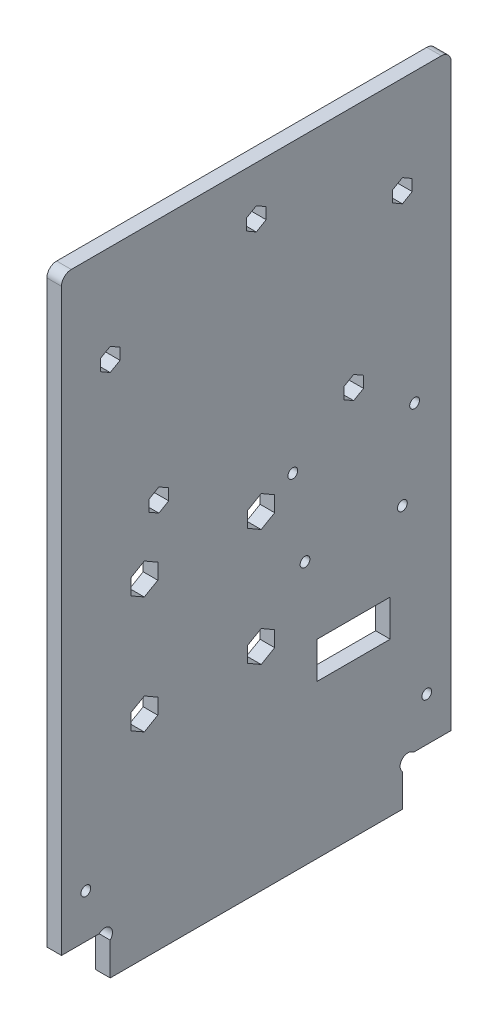
from build123d import *

# Parameters (mm, degrees)
EXTRUSION1_DEPTH        = 3
ESQUISSE2_R             = 1
ESQUISSE2_R_2           = 1.5
ENL_V_MAT_EXTRU_1_DEPTH = 4
ESQUISSE3_W             = 15
ESQUISSE3_H             = 7.5
ENL_V_MAT_EXTRU_2_DEPTH = 4
ESQUISSE4_R             = 1
ENL_V_MAT_EXTRU_3_DEPTH = 4
ENL_V_MAT_EXTRU_4_DEPTH = 4
CONG_1_R                = 2
ESQUISSE6_R             = 1
ENL_V_MAT_EXTRU_5_DEPTH = 4


with BuildPart() as part:
    # Esquisse1 → Extrusion1 (new body)
    with BuildSketch(Plane(origin=(0, 0, 0), x_dir=(0, 0, -1), z_dir=(1, 0, 0))):
        with BuildLine():
            Line((10, 6.7372583), (10, 0))
            Line((10, 0), (70, 0))
            Line((70, 0), (70, 6.7372583))
            ThreePointArc((70, 6.7372583), (70, 9), (72.2627417, 9))
            Line((72.2627417, 9), (80, 9))
            Line((80, 9), (80, 130))
            Line((80, 130), (0, 130))
            Line((0, 130), (0, 9))
            Line((0, 9), (7.7372583, 9))
            ThreePointArc((7.7372583, 9), (10, 9), (10, 6.7372583))
        make_face()
    extrude(amount=EXTRUSION1_DEPTH)

    # Esquisse2 → Enlèv. mat.-Extru.1 (cut, through all)
    with BuildSketch(Plane(origin=(3, 0, 0), x_dir=(0, 0, -1), z_dir=(1, 0, 0))):
        with Locations((60, 80)):
            Circle(ESQUISSE2_R)
        with Locations((10, 110)):
            Circle(ESQUISSE2_R)
        with Locations(Location((20, 80, 0), (0, 0, 180))):  # turned: the seam where the file's is
            Circle(ESQUISSE2_R)
        with Locations((70, 110)):
            Circle(ESQUISSE2_R)
        with Locations((17, 67.45)):
            Circle(ESQUISSE2_R_2)
        with Locations((17, 43.45)):
            Circle(ESQUISSE2_R_2)
        with Locations((41, 43.45)):
            Circle(ESQUISSE2_R_2)
        with Locations((41, 67.45)):
            Circle(ESQUISSE2_R_2)
        with Locations((40, 120)):
            Circle(ESQUISSE2_R)
        with Locations((70, 54)):
            Circle(ESQUISSE2_R)
        with Locations((50, 54)):
            Circle(ESQUISSE2_R)
    extrude(amount=-ENL_V_MAT_EXTRU_1_DEPTH, mode=Mode.SUBTRACT)

    # Esquisse3 → Enlèv. mat.-Extru.2 (cut, through all)
    with BuildSketch(Plane.ZY):
        with Locations((-60, 35.25)):
            Rectangle(ESQUISSE3_W, ESQUISSE3_H)
    extrude(amount=-ENL_V_MAT_EXTRU_2_DEPTH, mode=Mode.SUBTRACT)

    # Esquisse4 → Enlèv. mat.-Extru.3 (cut, through all)
    with BuildSketch(Plane(origin=(3, 0, 0), x_dir=(0, 0, -1), z_dir=(1, 0, 0))):
        with Locations((75, 18)):
            Circle(ESQUISSE4_R)
        with Locations((5, 18)):
            Circle(ESQUISSE4_R)
    extrude(amount=-ENL_V_MAT_EXTRU_3_DEPTH, mode=Mode.SUBTRACT)

    # Esquisse5 → Enlèv. mat.-Extru.4 (cut, through all)
    with BuildSketch(Plane(origin=(3, 0, 0), x_dir=(0, 0, -1), z_dir=(1, 0, 0))):
        Polygon((12.017839191, 111.165), (10, 112.33), (7.982160809, 111.165), (7.982160809, 108.835), (10, 107.67), (12.017839191, 108.835), align=None)
        Polygon((42.017839191, 118.835), (42.017839191, 121.165), (40, 122.33), (37.982160809, 121.165), (37.982160809, 118.835), (40, 117.67), align=None)
        Polygon((70, 107.67), (72.017839191, 108.835), (72.017839191, 111.165), (70, 112.33), (67.982160809, 111.165), (67.982160809, 108.835), align=None)
        Polygon((62.017839191, 78.835), (62.017839191, 81.165), (60, 82.33), (57.982160809, 81.165), (57.982160809, 78.835), (60, 77.67), align=None)
        Polygon((22.017839191, 78.835), (22.017839191, 81.165), (20, 82.33), (17.982160809, 81.165), (17.982160809, 78.835), (20, 77.67), align=None)
        Polygon((43.771281292, 65.85), (43.771281292, 69.05), (41, 70.65), (38.228718708, 69.05), (38.228718708, 65.85), (41, 64.25), align=None)
        Polygon((43.771281292, 41.85), (43.771281292, 45.05), (41, 46.65), (38.228718708, 45.05), (38.228718708, 41.85), (41, 40.25), align=None)
        Polygon((19.771281292, 41.85), (19.771281292, 45.05), (17, 46.65), (14.228718708, 45.05), (14.228718708, 41.85), (17, 40.25), align=None)
        Polygon((19.771281292, 65.85), (19.771281292, 69.05), (17, 70.65), (14.228718708, 69.05), (14.228718708, 65.85), (17, 64.25), align=None)
    extrude(amount=-ENL_V_MAT_EXTRU_4_DEPTH, mode=Mode.SUBTRACT)

    # Congé1
    cong_1_edges = [part.edges().sort_by_distance(p)[0] for p in [
        (1.5, 130, 0),
        (1.5, 130, -80),
    ]]
    fillet(cong_1_edges, radius=CONG_1_R)

    # Esquisse6 → Enlèv. mat.-Extru.5 (cut, through all)
    with BuildSketch(Plane.ZY):
        with Locations((-72.5, 71)):
            Circle(ESQUISSE6_R)
        with Locations((-47.5, 71)):
            Circle(ESQUISSE6_R)
    extrude(amount=-ENL_V_MAT_EXTRU_5_DEPTH, mode=Mode.SUBTRACT)


solid = part.part
